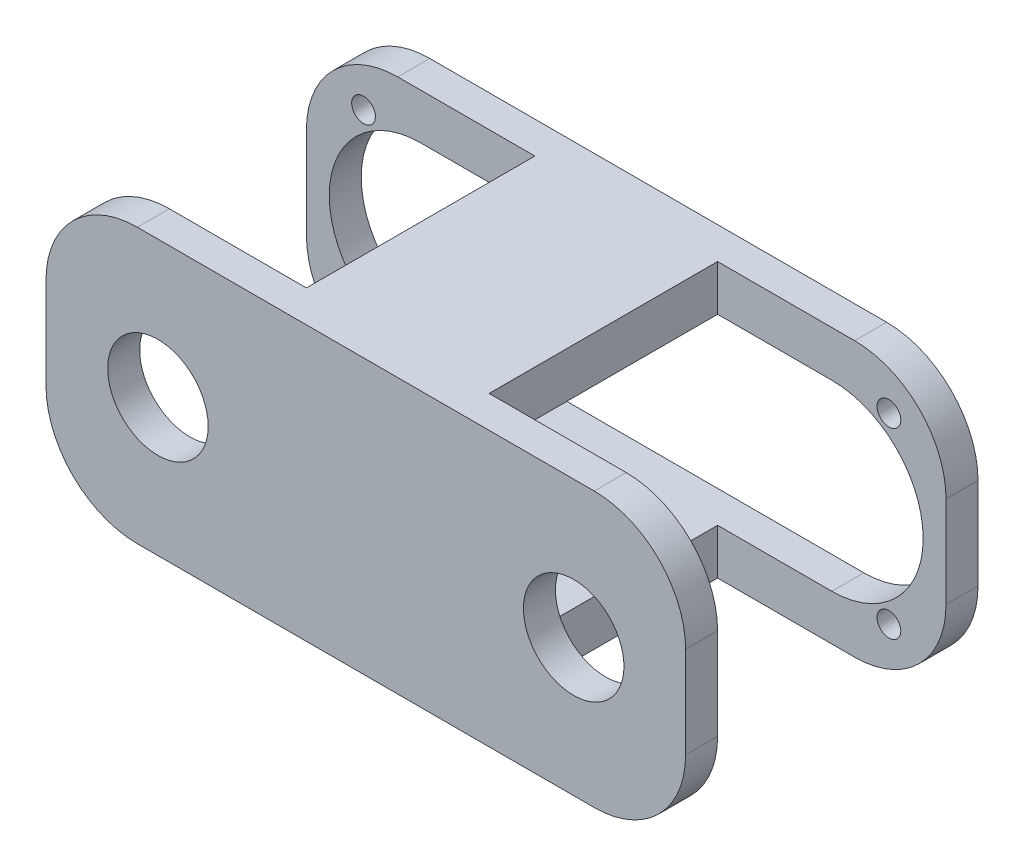
from build123d import *

# Parameters (mm, degrees)
BOSS_EXTRUDE1_DEPTH = 7
SKETCH3_W           = 40
SKETCH3_H           = 10
BOSS_EXTRUDE2_DEPTH = 50
SKETCH4_R           = 11
BOSS_EXTRUDE3_DEPTH = 7
SKETCH6_R           = 2.6
CUT_EXTRUDE1_DEPTH  = 7


with BuildPart() as part:
    # Sketch2 → Boss-Extrude1 (new body)
    with BuildSketch(Plane.XY):
        with BuildLine():
            Line((-20, 0), (-120, 0))
            ThreePointArc((-120, 0), (-134.142135624, 5.857864376), (-140, 20))
            Line((-140, 20), (-140, 40))
            ThreePointArc((-140, 40), (-134.142135624, 54.142135624), (-120, 60))
            Line((-120, 60), (-20, 60))
            ThreePointArc((-20, 60), (-5.857864376, 54.142135624), (0, 40))
            Line((0, 40), (0, 20))
            ThreePointArc((0, 20), (-5.857864376, 5.857864376), (-20, 0))
        make_face()
        with BuildLine():
            Line((-115, 50), (-25, 50))
            ThreePointArc((-25, 50), (-10.857864376, 44.142135624), (-5, 30))
            ThreePointArc((-5, 30), (-10.857864376, 15.857864376), (-25, 10))
            Line((-25, 10), (-115, 10))
            ThreePointArc((-115, 10), (-129.142135624, 15.857864376), (-135, 30))
            ThreePointArc((-135, 30), (-129.142135624, 44.142135624), (-115, 50))
        make_face(mode=Mode.SUBTRACT)
    extrude(amount=BOSS_EXTRUDE1_DEPTH)

    # Sketch3 → Boss-Extrude2 (add)
    with BuildSketch(Plane.XY.offset(7)):
        with Locations((-70, 55)):
            Rectangle(SKETCH3_W, SKETCH3_H)
        with Locations((-70, 5)):
            Rectangle(SKETCH3_W, SKETCH3_H)
    extrude(amount=BOSS_EXTRUDE2_DEPTH)

    # Sketch4 → Boss-Extrude3 (add)
    with BuildSketch(Plane.XY.offset(57)):
        with BuildLine():
            Line((-120, 60), (-20, 60))
            ThreePointArc((-20, 60), (-5.857864376, 54.142135624), (0, 40))
            Line((0, 40), (0, 20))
            ThreePointArc((0, 20), (-5.857864376, 5.857864376), (-20, 0))
            Line((-20, 0), (-120, 0))
            ThreePointArc((-120, 0), (-134.142135624, 5.857864376), (-140, 20))
            Line((-140, 20), (-140, 40))
            ThreePointArc((-140, 40), (-134.142135624, 54.142135624), (-120, 60))
        make_face()
        with Locations((-115.5, 30)):
            Circle(SKETCH4_R, mode=Mode.SUBTRACT)
        with Locations((-24.5, 30)):
            Circle(SKETCH4_R, mode=Mode.SUBTRACT)
    extrude(amount=BOSS_EXTRUDE3_DEPTH)

    # Sketch6 → Cut-Extrude1 (cut)
    with BuildSketch(Plane(origin=(0, 0, 0), x_dir=(-1, 0, 0), z_dir=(0, 0, -1))):
        with Locations((12.5, 50)):
            Circle(SKETCH6_R)
        with Locations((127.5, 50)):
            Circle(SKETCH6_R)
        with Locations((127.5, 10)):
            Circle(SKETCH6_R)
        with Locations((12.5, 10)):
            Circle(SKETCH6_R)
    extrude(amount=-CUT_EXTRUDE1_DEPTH, mode=Mode.SUBTRACT)


solid = part.part
